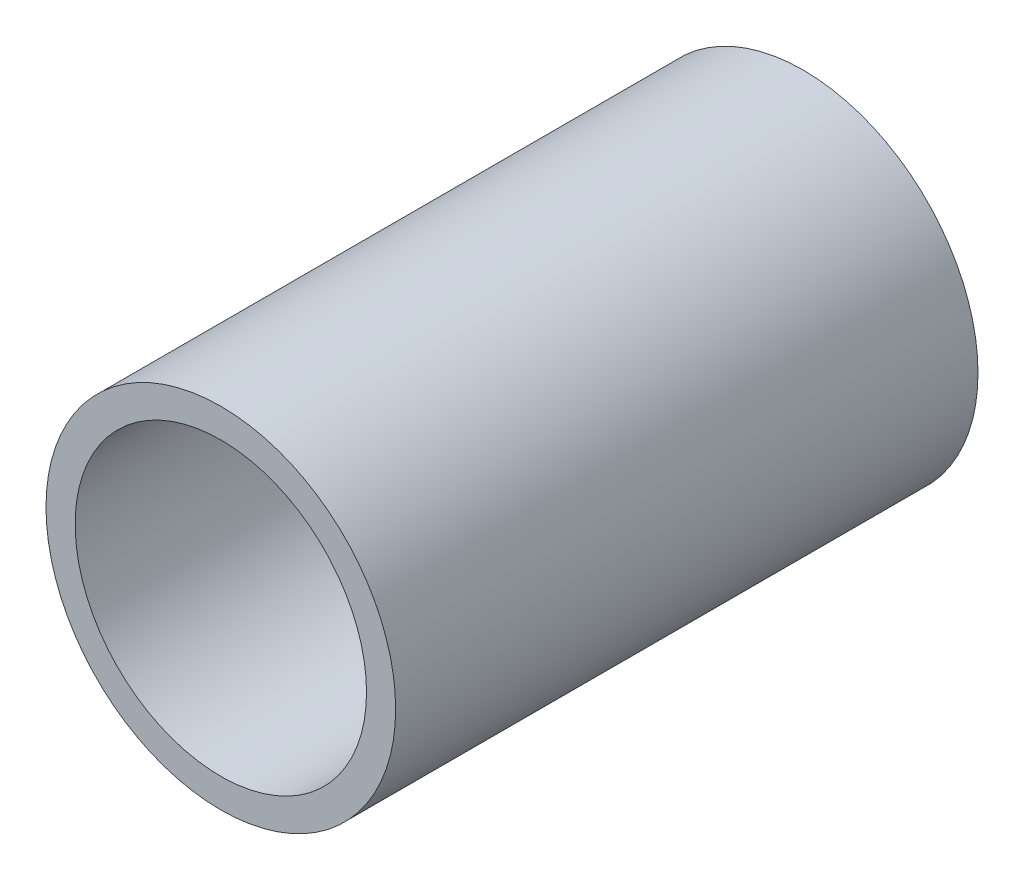
from build123d import *

# Parameters (mm, degrees)
SKETCH1_R      = 19.0627
SKETCH1_R_2    = 15.8877
EXTRUDE1_DEPTH = 31.75


with BuildPart() as part:
    # Sketch1 → Extrude1 (new body, symmetric)
    with BuildSketch(Plane.XY):
        Circle(SKETCH1_R)
        Circle(SKETCH1_R_2, mode=Mode.SUBTRACT)
    extrude(amount=EXTRUDE1_DEPTH, both=True)


solid = part.part
